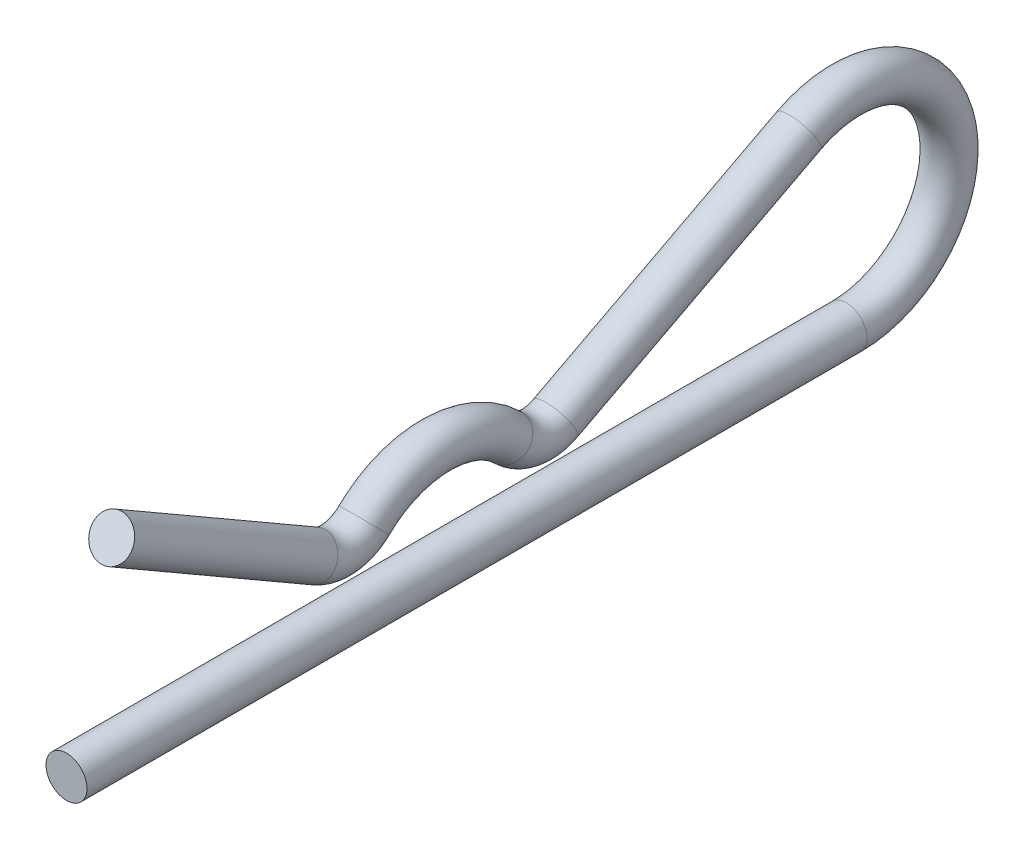
from build123d import *

# Parameters (mm, degrees)
SKETCH1_R = 0.79375


with BuildPart() as part:
    # Sweep1: sweep along a path in Sketch2
    with BuildLine(Plane(origin=(0, 0, 0), x_dir=(0, 0, -1), z_dir=(1, 0, 0))) as sweep1_path:
        Line((0, 0), (30.1625, 0))
        ThreePointArc((30.1625, 0), (34.016556239, 4.915970709), (28.322806453, 7.485354074))
        Line((28.322806453, 7.485354074), (18.911942386, 2.56210837))
        ThreePointArc((18.911942386, 2.56210837), (17.944168821, 2.398278597), (17.065046405, 2.834821429))
        ThreePointArc((17.065046405, 2.834821429), (14.2875, 3.96875), (11.509953595, 2.834821429))
        ThreePointArc((11.509953595, 2.834821429), (10.598111946, 2.393794506), (9.605185033, 2.593934671))
        Line((9.605185033, 2.593934671), (1.74625, 7.131292929))
    # Sketch1 → Sweep1 (sweep)
    with BuildSketch(Plane.XY):
        Circle(SKETCH1_R)
    sweep(path=sweep1_path.line)


solid = part.part
